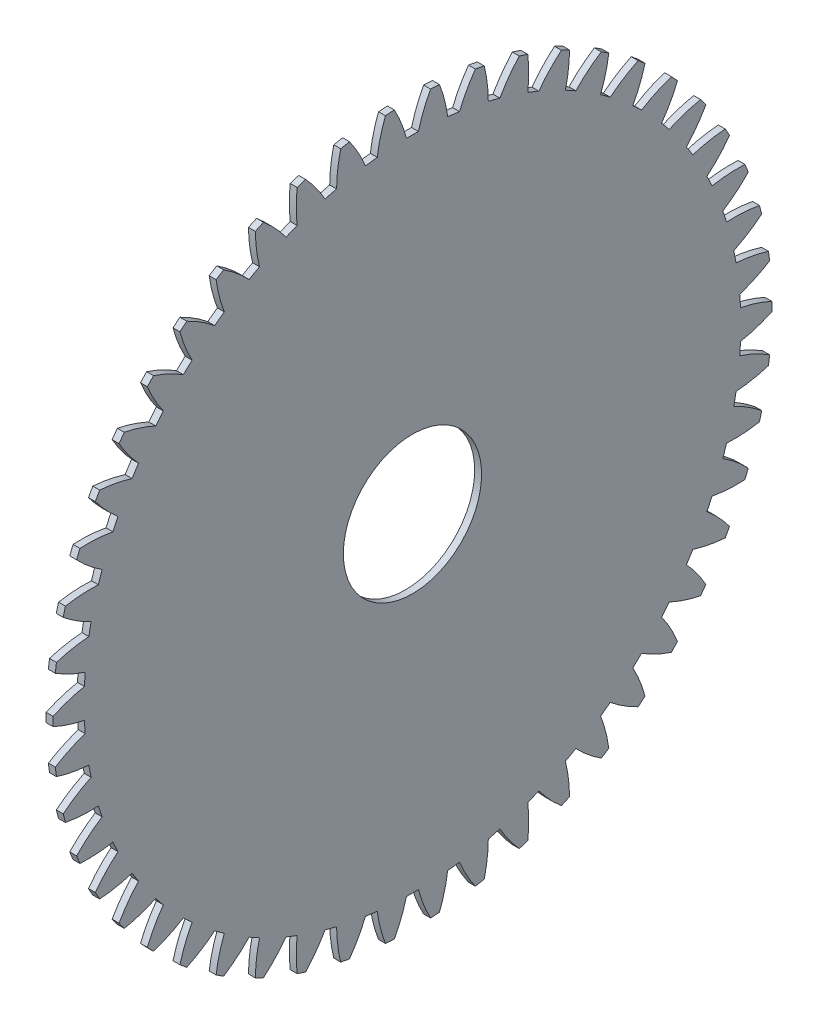
from build123d import *

# Parameters (mm, degrees)
BASPROSKE_W     = 3
BASPROSKE_H     = 156
TOOTHCUT_DEPTH  = 221.637712098
TEETHCUTS_COUNT = 50
TEETHCUTS_ANGLE = 352.8
BORSKE_R        = 30
BORE_DEPTH      = 50.0000508


with BuildPart() as part:
    # BasProSke → Base-Revolve (revolve)
    with BuildSketch(Plane(origin=(0, 0, 0), x_dir=(1, 0, 0), z_dir=(0, 1, 0)), mode=Mode.PRIVATE) as base_revolve_sk:
        with Locations((1.5, 78)):
            Rectangle(BASPROSKE_W, BASPROSKE_H)
    revolve(base_revolve_sk.sketch.rotate(Axis((-10, 0, 0), (1, 0, 0)), 180), axis=Axis((-10, 0, 0), (1, 0, 0)))

    # TooCutSke → ToothCut (cut, through all)
    with BuildSketch(Plane(origin=(0, 0, 0), x_dir=(0, 0, -1), z_dir=(1, 0, 0))):
        with BuildLine():
            ThreePointArc((2.592366304, 142.475417662), (0, 142.499), (-2.592366304, 142.475417662))
            ThreePointArc((-2.592366304, 142.475417662), (-4.830976585, 149.309534509), (-7.871151842, 155.826732025))
            ThreePointArc((-7.871151842, 155.826732025), (0, 156.0254), (7.871151842, 155.826732025))
            ThreePointArc((7.871151842, 155.826732025), (4.830976585, 149.309534509), (2.592366304, 142.475417662))
        make_face()
    toothcut = extrude(amount=TOOTHCUT_DEPTH, mode=Mode.SUBTRACT)

    # TeethCuts: ToothCut ×50 about axis
    teethcuts_axis = Axis((-10, 0, 0), (1, 0, 0))
    for i in range(1, TEETHCUTS_COUNT):
        add(toothcut.rotate(teethcuts_axis, i * TEETHCUTS_ANGLE / (TEETHCUTS_COUNT - 1)), mode=Mode.SUBTRACT)

    # BorSke → Bore (cut, symmetric)
    with BuildSketch(Plane(origin=(0, 0, 0), x_dir=(0, 0, -1), z_dir=(1, 0, 0))):
        with Locations(Location((0, 0, 0), (0, 0, 180))):
            Circle(BORSKE_R)
    extrude(amount=BORE_DEPTH, both=True, mode=Mode.SUBTRACT)


solid = part.part
